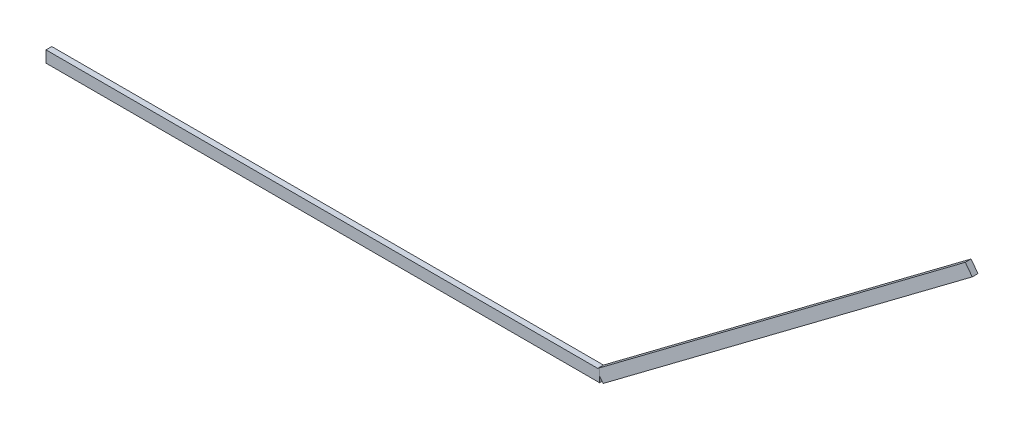
from build123d import *

# Parameters (mm, degrees)
SKETCH1_W                                      = 19.05
SKETCH1_H                                      = 38.1
C_PROGRAM_FILES_SOLIDWORKS_CORP_SOLIDWOR_DEPTH = 1828.8
SKETCH1_ON_SEGMENT_2_W                         = 19.05
SKETCH1_ON_SEGMENT_2_H                         = 38.1
C_PROGRAM_FILES_SOLIDWORKS_CORP_SOLI_2_DEPTH   = 1524


with BuildPart() as part:
    # Sketch1 → C_PROGRAM FILES_SOLIDWORKS CORP_SOLIDWOR (new body)
    with BuildSketch(Plane(origin=(0, 0, 0), x_dir=(0, 0, 1), z_dir=(1, 0, 0))):
        Rectangle(SKETCH1_W, SKETCH1_H)
    extrude(amount=C_PROGRAM_FILES_SOLIDWORKS_CORP_SOLIDWOR_DEPTH)


with BuildPart() as body_2:
    # Sketch1 on segment 2 (carried to segment 2) → C_PROGRAM FILES_SOLIDWORKS CORP_SOLI 2 (new body)
    with BuildSketch(Plane(origin=(1828.8, 0, 0), x_dir=(0, 0, 1), z_dir=(0.8, 0.6, 0))):
        Rectangle(SKETCH1_ON_SEGMENT_2_W, SKETCH1_ON_SEGMENT_2_H)
    extrude(amount=C_PROGRAM_FILES_SOLIDWORKS_CORP_SOLI_2_DEPTH)


solid = Compound([part.part, body_2.part])
